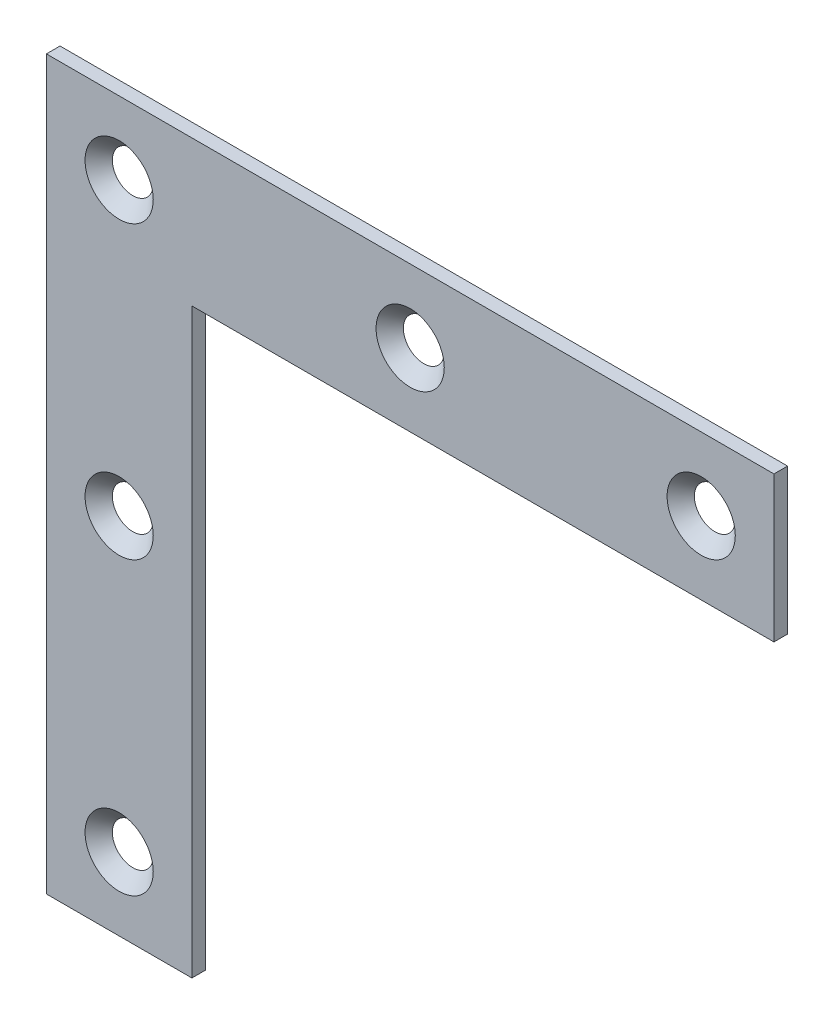
from build123d import *

# Parameters (mm, degrees)
SKETCH1_W           = 80
SKETCH1_H           = 80
BOSS_EXTRUDE1_DEPTH = 1.5
SKETCH2_W           = 64
SKETCH2_H           = 64
CUT_EXTRUDE1_DEPTH  = 2.5
HOLE1_AT_2_COUNT    = 2
HOLE1_AT_2_PITCH    = 32
HOLE1_AT_3_COUNT    = 2
HOLE1_AT_3_PITCH    = 64
HOLE1_AT_4_COUNT    = 2
HOLE1_AT_4_PITCH    = 32
HOLE1_AT_5_COUNT    = 2
HOLE1_AT_5_PITCH    = 64


with BuildPart() as part:
    # Sketch1 → Boss-Extrude1 (new body)
    with BuildSketch(Plane.XY.offset(1.5)):
        with Locations((40, -40)):
            Rectangle(SKETCH1_W, SKETCH1_H)
    extrude(amount=-BOSS_EXTRUDE1_DEPTH)

    # Sketch2 → Cut-Extrude1 (cut, through all)
    with BuildSketch(Plane(origin=(0, 0, 0), x_dir=(-1, 0, 0), z_dir=(0, 0, -1))):
        with Locations((-48, -48)):
            Rectangle(SKETCH2_W, SKETCH2_H)
    extrude(amount=-CUT_EXTRUDE1_DEPTH, mode=Mode.SUBTRACT)

    # Sketch3 → Hole1 (revolve, cut)
    with BuildSketch(Plane(origin=(8, -8, 1.5), x_dir=(0, -1, 0), z_dir=(1, 0, 0))):
        Polygon((0, 0), (0, 1.5), (2.25, 1.5), (3.75, 0), align=None)
    hole1 = revolve(axis=Axis((8, -8, -108.5), (0, 0, 1)), mode=Mode.SUBTRACT)

    # Hole1 at 2: Hole1 ×2
    with Locations(*[(i * HOLE1_AT_2_PITCH, 0, 0) for i in range(1, HOLE1_AT_2_COUNT)]):
        add(hole1, mode=Mode.SUBTRACT)

    # Hole1 at 3: Hole1 ×2
    with Locations(*[(i * HOLE1_AT_3_PITCH, 0, 0) for i in range(1, HOLE1_AT_3_COUNT)]):
        add(hole1, mode=Mode.SUBTRACT)

    # Hole1 at 4: Hole1 ×2
    with Locations(*[(0, -i * HOLE1_AT_4_PITCH, 0) for i in range(1, HOLE1_AT_4_COUNT)]):
        add(hole1, mode=Mode.SUBTRACT)

    # Hole1 at 5: Hole1 ×2
    with Locations(*[(0, -i * HOLE1_AT_5_PITCH, 0) for i in range(1, HOLE1_AT_5_COUNT)]):
        add(hole1, mode=Mode.SUBTRACT)


solid = part.part
